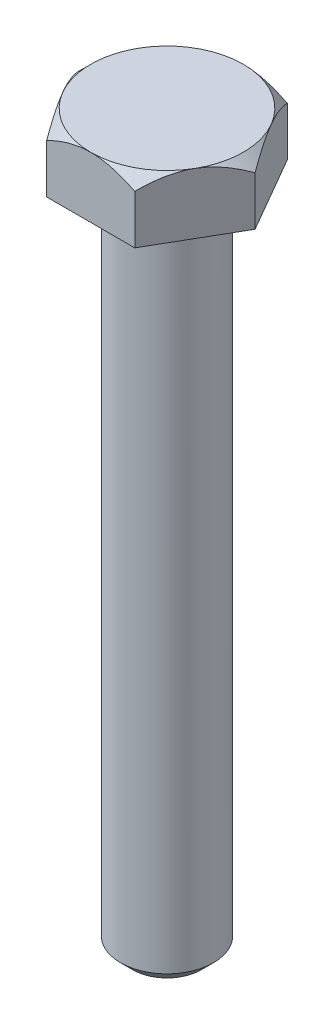
from build123d import *

# Parameters (mm, degrees)
EXTRUDE_1_DEPTH     = 5
SKETCH_8_OUTSIDE_W  = 22.464
SKETCH_8_OUTSIDE_H  = 20.522
SKETCH_8_OUTSIDE_R  = 6.278684177
CUT_EXTRUDE_1_DEPTH = 1
CUT_EXTRUDE_1_TAPER = 45
SKETCH_9_R          = 3.825
BOLT_LENGTH_DEPTH   = 55
FILLET_1_R          = 1
CHAMFER_1_SIZE      = 1


with BuildPart() as part:
    # Эскиз6 → Бобышка-Вытянуть1 (new body)
    with BuildSketch(Plane(origin=(0, 0, 0), x_dir=(1, 0, 0), z_dir=(0, 1, 0))):
        Polygon((7.25, 0), (3.625, 6.278684177), (-3.625, 6.278684177), (-7.25, 0), (-3.625, -6.278684177), (3.625, -6.278684177), align=None)
    extrude(amount=EXTRUDE_1_DEPTH)

    # Эскиз8 outside → Вырез-Вытянуть1 (cut)
    with BuildSketch(Plane(origin=(0, 5, 0), x_dir=(1, 0, 0), z_dir=(0, 1, 0))):
        Rectangle(SKETCH_8_OUTSIDE_W, SKETCH_8_OUTSIDE_H)
        Circle(SKETCH_8_OUTSIDE_R, mode=Mode.SUBTRACT)
    extrude(amount=-CUT_EXTRUDE_1_DEPTH, taper=CUT_EXTRUDE_1_TAPER, mode=Mode.SUBTRACT)

    # Эскиз9 → bolt length (add)
    with BuildSketch(Plane.XZ):
        Circle(SKETCH_9_R)
    extrude(amount=BOLT_LENGTH_DEPTH)

    # Скругление1
    fillet_1_edges = [part.edges().sort_by_distance(p)[0] for p in [
        (-3.825, 0, 0),
    ]]
    fillet(fillet_1_edges, radius=FILLET_1_R)

    # Фаска1
    chamfer_1_edges = [part.edges().sort_by_distance(p)[0] for p in [
        (-3.825, -55, 0),
    ]]
    chamfer(chamfer_1_edges, length=CHAMFER_1_SIZE)


solid = part.part
